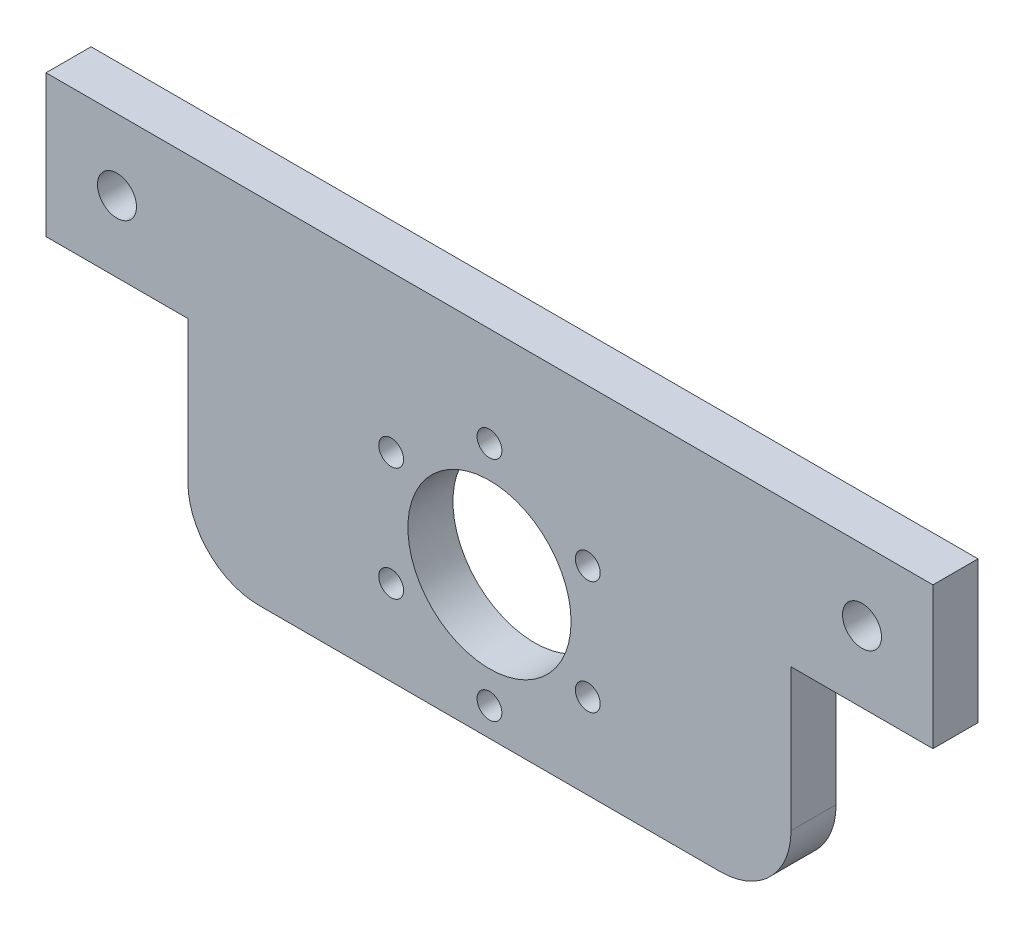
from build123d import *

# Parameters (mm, degrees)
SKETCH1_W           = 125
SKETCH1_H           = 50
BOSS_EXTRUDE1_DEPTH = 6.35
SKETCH2_R           = 11.5
CUT_EXTRUDE1_DEPTH  = 7.35
SKETCH5_R           = 1.75
CUT_EXTRUDE5_DEPTH  = 7.35
SKETCH6_R           = 2.75
SKETCH6_W           = 20
SKETCH6_H           = 30
CUT_EXTRUDE6_DEPTH  = 7.35
FILLET1_R           = 10


with BuildPart() as part:
    # Sketch1 → Boss-Extrude1 (new body)
    with BuildSketch(Plane.XY):
        with Locations((62.5, 25)):
            Rectangle(SKETCH1_W, SKETCH1_H)
    extrude(amount=BOSS_EXTRUDE1_DEPTH)

    # Sketch2 → Cut-Extrude1 (cut, through all)
    with BuildSketch(Plane.XY.offset(6.35)):
        with Locations((62.5, 20)):
            Circle(SKETCH2_R)
    extrude(amount=-CUT_EXTRUDE1_DEPTH, mode=Mode.SUBTRACT)

    # Sketch5 → Cut-Extrude5 (cut, through all)
    with BuildSketch(Plane(origin=(0, 0, 0), x_dir=(-1, 0, 0), z_dir=(0, 0, -1))):
        with Locations((-48.643593539, 28)):
            Circle(SKETCH5_R)
        with Locations((-48.643593539, 12)):
            Circle(SKETCH5_R)
        with Locations((-62.5, 4)):
            Circle(SKETCH5_R)
        with Locations((-76.356406461, 12)):
            Circle(SKETCH5_R)
        with Locations((-76.356406461, 28)):
            Circle(SKETCH5_R)
        with Locations((-62.5, 36)):
            Circle(SKETCH5_R)
    extrude(amount=-CUT_EXTRUDE5_DEPTH, mode=Mode.SUBTRACT)

    # Sketch6 → Cut-Extrude6 (cut, through all)
    with BuildSketch(Plane(origin=(0, 0, 0), x_dir=(-1, 0, 0), z_dir=(0, 0, -1))):
        with Locations((-115, 40)):
            Circle(SKETCH6_R)
        with Locations((-10, 40)):
            Circle(SKETCH6_R)
        with Locations((-115, 15)):
            Rectangle(SKETCH6_W, SKETCH6_H)
        with Locations((-10, 15)):
            Rectangle(SKETCH6_W, SKETCH6_H)
    extrude(amount=-CUT_EXTRUDE6_DEPTH, mode=Mode.SUBTRACT)

    # Fillet1
    fillet1_edges = [part.edges().sort_by_distance(p)[0] for p in [
        (105, 0, 3.175),
        (20, 0, 3.175),
    ]]
    fillet(fillet1_edges, radius=FILLET1_R)


solid = part.part
